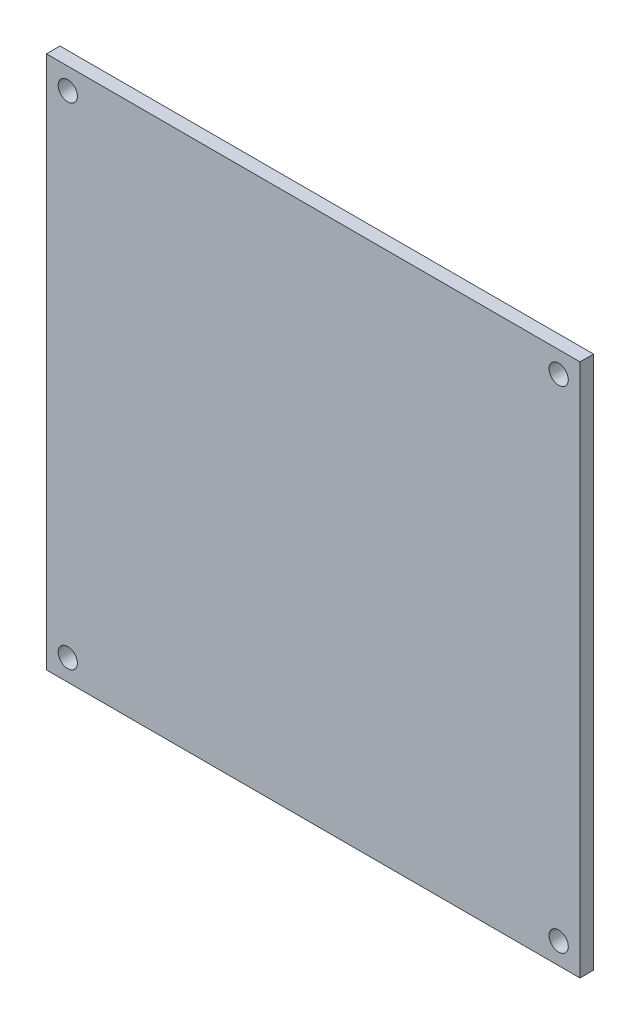
from build123d import *

# Parameters (mm, degrees)
SKETCH1_W           = 125
SKETCH1_H           = 125
BOSS_EXTRUDE1_DEPTH = 3.175
SKETCH2_R           = 2.25
CUT_EXTRUDE2_DEPTH  = 3.175


with BuildPart() as part:
    # Sketch1 → Boss-Extrude1 (new body)
    with BuildSketch(Plane.XY):
        Rectangle(SKETCH1_W, SKETCH1_H)
    extrude(amount=BOSS_EXTRUDE1_DEPTH)

    # Sketch2 → Cut-Extrude2 (cut)
    with BuildSketch(Plane.XY.offset(3.175)):
        with Locations((-57.5, 57.5)):
            Circle(SKETCH2_R)
        with Locations((-57.5, -57.5)):
            Circle(SKETCH2_R)
        with Locations((57.5, -57.5)):
            Circle(SKETCH2_R)
        with Locations((57.5, 57.5)):
            Circle(SKETCH2_R)
    extrude(amount=-CUT_EXTRUDE2_DEPTH, mode=Mode.SUBTRACT)


solid = part.part
